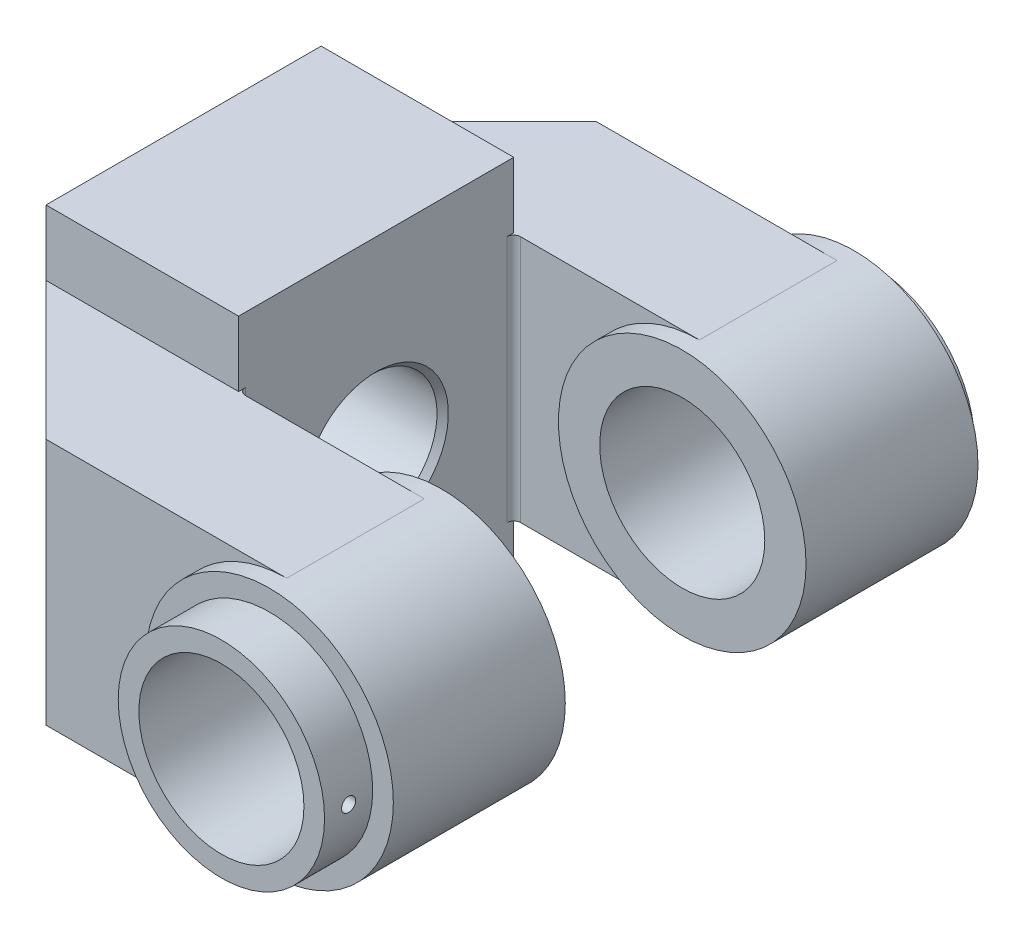
from build123d import *

# Parameters (mm, degrees)
SKETCH_1_W          = 56
SKETCH_1_H          = 110
EXTRUDE_1_DEPTH     = 40
SKETCH_3_W          = 56
SKETCH_3_H          = 72
EXTRUDE_2_DEPTH     = 40
SKETCH_4_R          = 36
SKETCH_4_R_2        = 24
EXTRUDE_3_DEPTH     = 25
SKETCH_5_R          = 30
SKETCH_5_R_2        = 24
EXTRUDE_4_DEPTH     = 5
CHAMFER_1_SIZE      = 40
FILLET_1_R          = 2
SKETCH_6_R          = 19.352
CUT_EXTRUDE_1_DEPTH = 147
CHAMFER_2_SIZE      = 1.648
SKETCH_7_R          = 30
SKETCH_7_R_2        = 24
EXTRUDE_5_DEPTH     = 9
SKETCH_8_R          = 2.05
CUT_EXTRUDE_2_DEPTH = 37


with BuildPart() as part:
    # Эскиз1 → Бобышка-Вытянуть1 (new body)
    with BuildSketch(Plane.XY):
        Rectangle(SKETCH_1_W, SKETCH_1_H)
    extrude(amount=EXTRUDE_1_DEPTH)

    # Эскиз3 → Бобышка-Вытянуть2 (add)
    with BuildSketch(Plane.XY.offset(40)):
        Rectangle(SKETCH_3_W, SKETCH_3_H)
        with BuildLine():
            Line((28, 36), (28, -36))
            Line((28, -36), (82, -36))
            ThreePointArc((82, -36), (46, 0), (82, 36))
            Line((82, 36), (28, 36))
        make_face()
        with BuildLine():
            ThreePointArc((82, 36), (46, 0), (82, -36))
            Line((82, -36), (82, -24))
            ThreePointArc((82, -24), (58, 0), (82, 24))
            Line((82, 24), (82, 36))
        make_face()
        with BuildLine():
            Line((82, -24), (82, -36))
            ThreePointArc((82, -36), (107.455844, -25.455844), (118, 0))
            ThreePointArc((118, 0), (107.455844, 25.455844), (82, 36))
            Line((82, 36), (82, 24))
            ThreePointArc((82, 24), (98.970563, 16.970563), (106, 0))
            ThreePointArc((106, 0), (98.970563, -16.970563), (82, -24))
        make_face()
    extrude(amount=EXTRUDE_2_DEPTH)

    # Эскиз4 → Бобышка-Вытянуть3 (add, symmetric)
    with BuildSketch(Plane.XY.offset(60)):
        with Locations((82, 0)):
            Circle(SKETCH_4_R)
        with Locations((82, 0)):
            Circle(SKETCH_4_R_2, mode=Mode.SUBTRACT)
    extrude(amount=EXTRUDE_3_DEPTH, both=True)

    # Эскиз5 → Бобышка-Вытянуть4 (add)
    with BuildSketch(Plane.XY.offset(85)):
        with Locations((82, 0)):
            Circle(SKETCH_5_R)
        with Locations((82, 0)):
            Circle(SKETCH_5_R_2, mode=Mode.SUBTRACT)
    extrude(amount=EXTRUDE_4_DEPTH)

    # Фаска1
    chamfer_1_edges = [part.edges().sort_by_distance(p)[0] for p in [
        (-28, 0, 80),
    ]]
    chamfer(chamfer_1_edges, length=CHAMFER_1_SIZE)

    # Скругление1
    fillet_1_edges = [part.edges().sort_by_distance(p)[0] for p in [
        (28, 0, 40),
    ]]
    fillet(fillet_1_edges, radius=FILLET_1_R)

    # Зеркальное отражение1: part across plane


with BuildPart() as part_1:
    add(part.part)
    add(part.part.mirror(Plane(origin=(0, 0, 0), x_dir=(1, 0, 0), z_dir=(0, 0, -1))))

    # Эскиз6 → Вырез-Вытянуть1 (cut, through all)
    with BuildSketch(Plane.ZY.offset(28)):
        Circle(SKETCH_6_R)
    extrude(amount=-CUT_EXTRUDE_1_DEPTH, mode=Mode.SUBTRACT)

    # Фаска2
    chamfer_2_edges = [part_1.edges().sort_by_distance(p)[0] for p in [
        (28, -13.68393, 13.68393),
        (-28, 13.68393, 13.68393),
    ]]
    chamfer(chamfer_2_edges, length=CHAMFER_2_SIZE)

    # Эскиз7 → Бобышка-Вытянуть5 (add)
    with BuildSketch(Plane.XY.offset(90)):
        with Locations((82, 0)):
            Circle(SKETCH_7_R)
        with Locations((82, 0)):
            Circle(SKETCH_7_R_2, mode=Mode.SUBTRACT)
    extrude(amount=EXTRUDE_5_DEPTH)

    # Эскиз8 → Вырез-Вытянуть2 (cut, through all)
    with BuildSketch(Plane(origin=(82, 0, 0), x_dir=(0, 0, -1), z_dir=(1, 0, 0))):
        with Locations((-92, 0)):
            Circle(SKETCH_8_R)
    extrude(amount=CUT_EXTRUDE_2_DEPTH, mode=Mode.SUBTRACT)


solid = part_1.part
